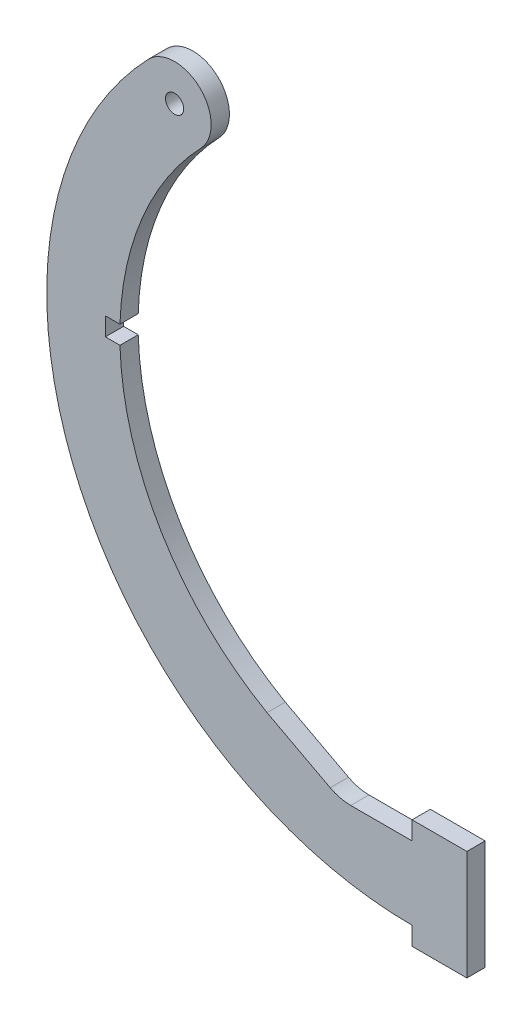
from build123d import *

# Parameters (mm, degrees)
SKETCH1_R           = 1.5875
BOSS_EXTRUDE1_DEPTH = 3.175


with BuildPart() as part:
    # Sketch1 → Boss-Extrude1 (new body)
    with BuildSketch(Plane.XY):
        with BuildLine():
            Line((145.943650407, -28.027444193), (145.943650407, -24.852444193))
            Line((145.943650407, -24.852444193), (152.293650407, -24.852444193))
            Line((152.293650407, -24.852444193), (155.468650407, -24.852444193))
            Line((155.468650407, -24.852444193), (155.468650407, -28.027444193))
            Line((155.468650407, -28.027444193), (155.468650407, -40.727444193))
            Line((155.468650407, -40.727444193), (155.468650407, -43.902444193))
            Line((155.468650407, -43.902444193), (145.943650407, -43.902444193))
            Line((145.943650407, -43.902444193), (145.943650407, -40.727444193))
            ThreePointArc((145.943650407, -40.727444193), (87.543306121, -2.160349908), (100.082539295, 66.693034944))
            ThreePointArc((100.082539295, 66.693034944), (109.06069832, 66.887098142), (109.254761518, 57.908939117))
            ThreePointArc((109.254761518, 57.908939117), (99.104850954, 42.438945049), (95.168461153, 24.360055807))
            Line((95.168461153, 24.360055807), (92.628461153, 24.360055807))
            Line((92.628461153, 24.360055807), (92.628461153, 21.185055807))
            Line((92.628461153, 21.185055807), (95.168461153, 21.185055807))
            ThreePointArc((95.168461153, 21.185055807), (95.286372211, 18.967274494), (95.501106091, 16.756766333))
            ThreePointArc((95.501106091, 16.756766333), (103.592613564, -5.281493426), (120.729197754, -21.328140077))
            Line((120.729197754, -21.328140077), (131.710241083, -27.141852582))
            ThreePointArc((131.710241083, -27.141852582), (133.438776966, -27.802732961), (135.275650407, -28.027444193))
            Line((135.275650407, -28.027444193), (145.943650407, -28.027444193))
        make_face()
        with Locations((104.668650407, 62.300987031)):
            Circle(SKETCH1_R, mode=Mode.SUBTRACT)
    extrude(amount=BOSS_EXTRUDE1_DEPTH)


solid = part.part
